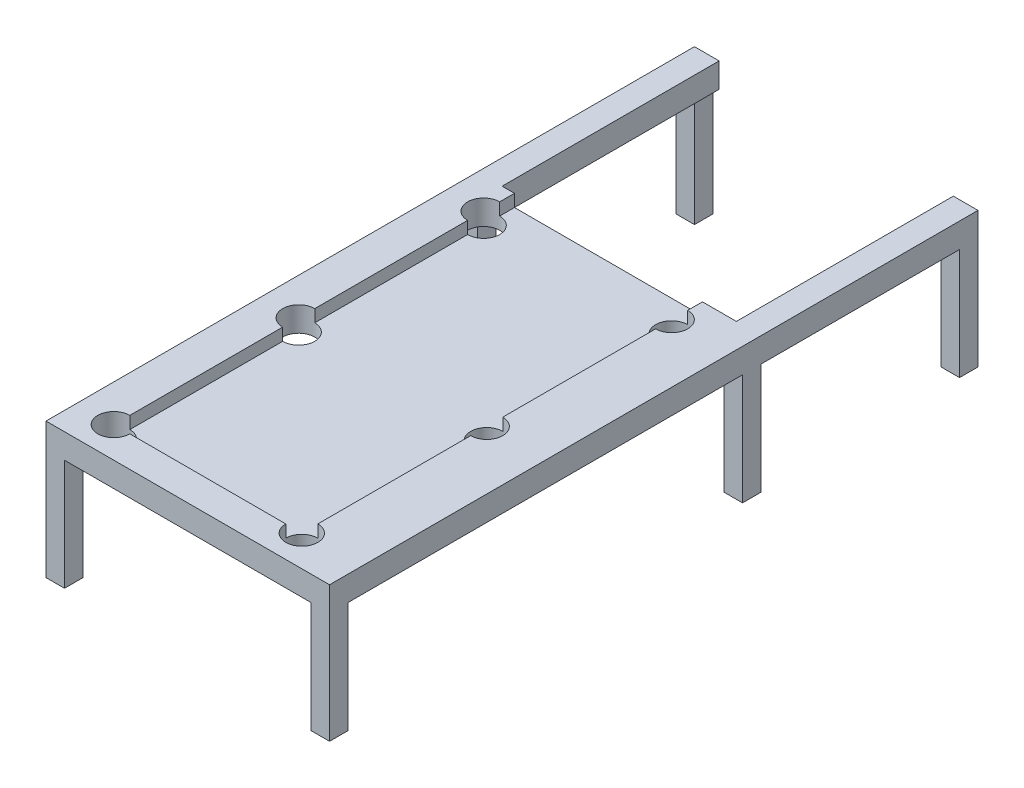
from build123d import *

# Parameters (mm, degrees)
SKETCH2_W           = 460
SKETCH2_H           = 700
SKETCH2_W_2         = 305
SKETCH2_H_2         = 600
BOSS_EXTRUDE1_DEPTH = 20
SKETCH10_W          = 460
SKETCH10_H          = 700
BOSS_EXTRUDE6_DEPTH = 20
SKETCH11_W          = 30
SKETCH11_H          = 30
BOSS_EXTRUDE7_DEPTH = 180
SKETCH14_W          = 40
SKETCH14_H          = 352
BOSS_EXTRUDE8_DEPTH = 40
SKETCH15_W          = 30
SKETCH15_H          = 30
BOSS_EXTRUDE9_DEPTH = 180
SKETCH17_R          = 26
CUT_EXTRUDE1_DEPTH  = 60
CUT_EXTRUDE2_DEPTH  = 20


with BuildPart() as part:
    # Sketch2 → Boss-Extrude1 (new body)
    with BuildSketch(Plane(origin=(0, 0, 0), x_dir=(1, 0, 0), z_dir=(0, 1, 0))):
        with Locations((230, 350)):
            Rectangle(SKETCH2_W, SKETCH2_H)
        with Locations((212.5, 350)):
            Rectangle(SKETCH2_W_2, SKETCH2_H_2, mode=Mode.SUBTRACT)
    extrude(amount=BOSS_EXTRUDE1_DEPTH)

    # Sketch10 → Boss-Extrude6 (add)
    with BuildSketch(Plane.XZ):
        with Locations((230, -350)):
            Rectangle(SKETCH10_W, SKETCH10_H)
    extrude(amount=BOSS_EXTRUDE6_DEPTH)

    # Sketch11 → Boss-Extrude7 (add)
    with BuildSketch(Plane.XZ.offset(20)):
        with Locations((15, -15)):
            Rectangle(SKETCH11_W, SKETCH11_H)
        with Locations((445, -15)):
            Rectangle(SKETCH11_W, SKETCH11_H)
        with Locations((15, -685)):
            Rectangle(SKETCH11_W, SKETCH11_H)
        with Locations((445, -685)):
            Rectangle(SKETCH11_W, SKETCH11_H)
    extrude(amount=BOSS_EXTRUDE7_DEPTH)

    # Sketch14 → Boss-Extrude8 (add)
    with BuildSketch(Plane(origin=(0, 20, 0), x_dir=(1, 0, 0), z_dir=(0, 1, 0))):
        with Locations((20, 876)):
            Rectangle(SKETCH14_W, SKETCH14_H)
        with Locations((440, 876)):
            Rectangle(SKETCH14_W, SKETCH14_H)
    extrude(amount=-BOSS_EXTRUDE8_DEPTH)

    # Sketch15 → Boss-Extrude9 (add)
    with BuildSketch(Plane.XZ.offset(20)):
        with Locations((445, -1037)):
            Rectangle(SKETCH15_W, SKETCH15_H)
        with Locations((15, -1037)):
            Rectangle(SKETCH15_W, SKETCH15_H)
    extrude(amount=BOSS_EXTRUDE9_DEPTH)

    # Sketch17 → Cut-Extrude1 (cut)
    with BuildSketch(Plane(origin=(0, 20, 0), x_dir=(1, 0, 0), z_dir=(0, 1, 0))):
        with BuildLine():
            Line((365, 650), (339, 650))
            ThreePointArc((339, 650), (346.615223689, 631.615223689), (365, 624))
            Line((365, 624), (365, 650))
        make_face()
        with BuildLine():
            ThreePointArc((391, 650), (365, 676), (339, 650))
            Line((339, 650), (365, 650))
            Line((365, 650), (365, 624))
            ThreePointArc((365, 624), (383.384776311, 631.615223689), (391, 650))
        make_face()
        with BuildLine():
            Line((365, 324), (365, 376))
            ThreePointArc((365, 376), (339, 350), (365, 324))
        make_face()
        with BuildLine():
            ThreePointArc((391, 350), (383.384776311, 368.384776311), (365, 376))
            Line((365, 376), (365, 324))
            ThreePointArc((365, 324), (383.384776311, 331.615223689), (391, 350))
        make_face()
        with BuildLine():
            Line((365, 50), (365, 76))
            ThreePointArc((365, 76), (346.615223689, 68.384776311), (339, 50))
            Line((339, 50), (365, 50))
        make_face()
        with BuildLine():
            ThreePointArc((391, 50), (383.384776311, 68.384776311), (365, 76))
            Line((365, 76), (365, 50))
            Line((365, 50), (339, 50))
            ThreePointArc((339, 50), (365, 24), (391, 50))
        make_face()
        with BuildLine():
            Line((60, 324), (60, 376))
            ThreePointArc((60, 376), (34, 350), (60, 324))
        make_face()
        with BuildLine():
            ThreePointArc((86, 350), (78.384776311, 368.384776311), (60, 376))
            Line((60, 376), (60, 324))
            ThreePointArc((60, 324), (78.384776311, 331.615223689), (86, 350))
        make_face()
        with BuildLine():
            Line((60, 50), (60, 76))
            ThreePointArc((60, 76), (41.615223689, 31.615223689), (86, 50))
            Line((86, 50), (60, 50))
        make_face()
        with BuildLine():
            ThreePointArc((86, 50), (78.384776311, 68.384776311), (60, 76))
            Line((60, 76), (60, 50))
            Line((60, 50), (86, 50))
        make_face()
        with Locations((60, 650)):
            Circle(SKETCH17_R)
    extrude(amount=-CUT_EXTRUDE1_DEPTH, mode=Mode.SUBTRACT)

    # Sketch18 → Cut-Extrude2 (cut)
    with BuildSketch(Plane(origin=(0, 20, 0), x_dir=(1, 0, 0), z_dir=(0, 1, 0))):
        Polygon((60, 700), (365, 700), (365, 650), (212.5, 650), (60, 650), align=None)
    extrude(amount=-CUT_EXTRUDE2_DEPTH, mode=Mode.SUBTRACT)


solid = part.part
